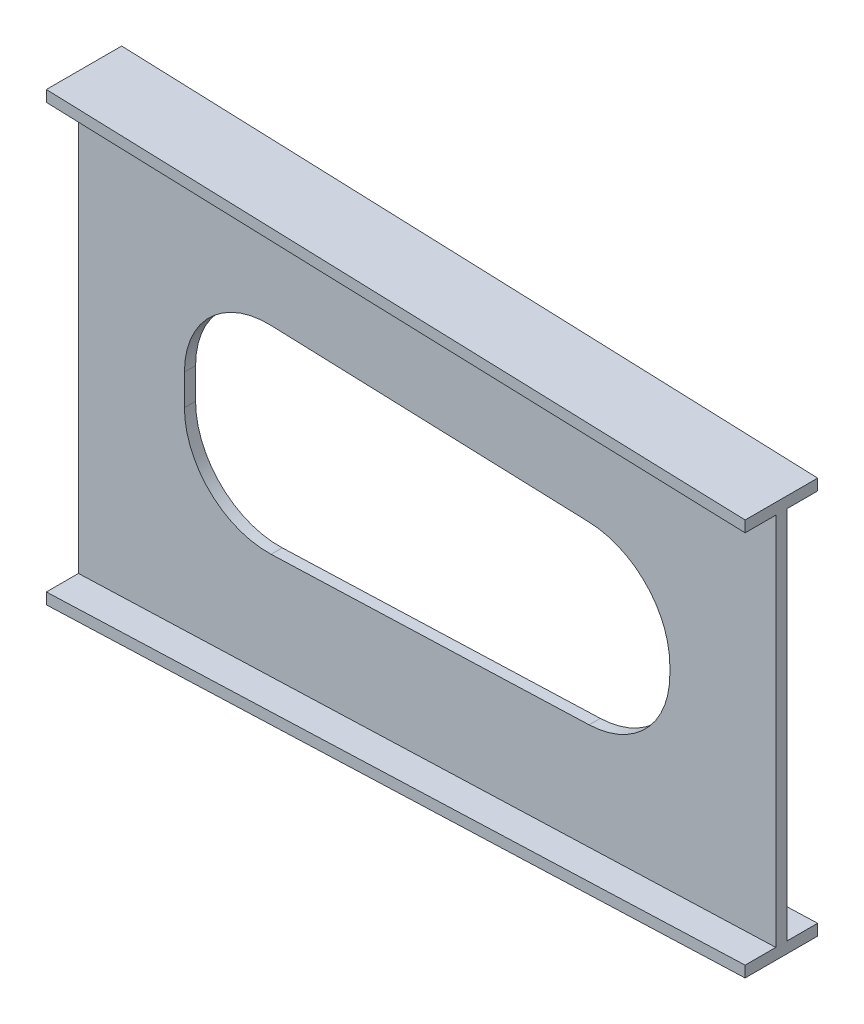
from build123d import *

# Parameters (mm, degrees)
CUT_EXTRUDE1_DEPTH = 78.5000001


with BuildPart() as part:
    # Sketch1 → Loft l1 section 0
    with BuildSketch(Plane(origin=(0, 0, 0), x_dir=(0, 0, -1), z_dir=(1, 0, 0))):
        Polygon((-77.5, 400), (57.5, 400), (57.5, 380), (0, 380), (0, -380), (57.5, -380), (57.5, -400), (-77.5, -400), (-77.5, -380), (-20, -380), (-20, 380), (-77.5, 380), align=None)
    # Sketch4 → Loft l1 section 1
    with BuildSketch(Plane(origin=(1250, 0, -1000), x_dir=(0, 0, 1), z_dir=(-1, 0, 0))):
        Polygon((945, 355.5), (1075, 355.5), (1075, 335.5), (1020, 335.5), (1020, -335.5), (1075, -335.5), (1075, -355.5), (945, -355.5), (945, -335.5), (1000, -335.5), (1000, 335.5), (945, 335.5), align=None)
    loft()

    # Sketch6 → Cut-Extrude1 (cut, through all)
    with BuildSketch(Plane.XY.offset(20)):
        with BuildLine():
            Line((345.336619362, -177.585655274), (915.336619362, -157.293655274))
            ThreePointArc((915.336619362, -157.293655274), (1017.936307386, -111.550767286), (1060, -7.38861702))
            Line((1060, -7.38861702), (1060, 7.38861702))
            ThreePointArc((1060, 7.38861702), (1017.936307386, 111.550767286), (915.336619362, 157.293655274))
            Line((915.336619362, 157.293655274), (345.336619362, 177.585655274))
            ThreePointArc((345.336619362, 177.585655274), (235.837849735, 135.616924406), (190, 27.68061702))
            Line((190, 27.68061702), (190, -27.68061702))
            ThreePointArc((190, -27.68061702), (235.837849735, -135.616924406), (345.336619362, -177.585655274))
        make_face()
    extrude(amount=-CUT_EXTRUDE1_DEPTH, mode=Mode.SUBTRACT)


solid = part.part
